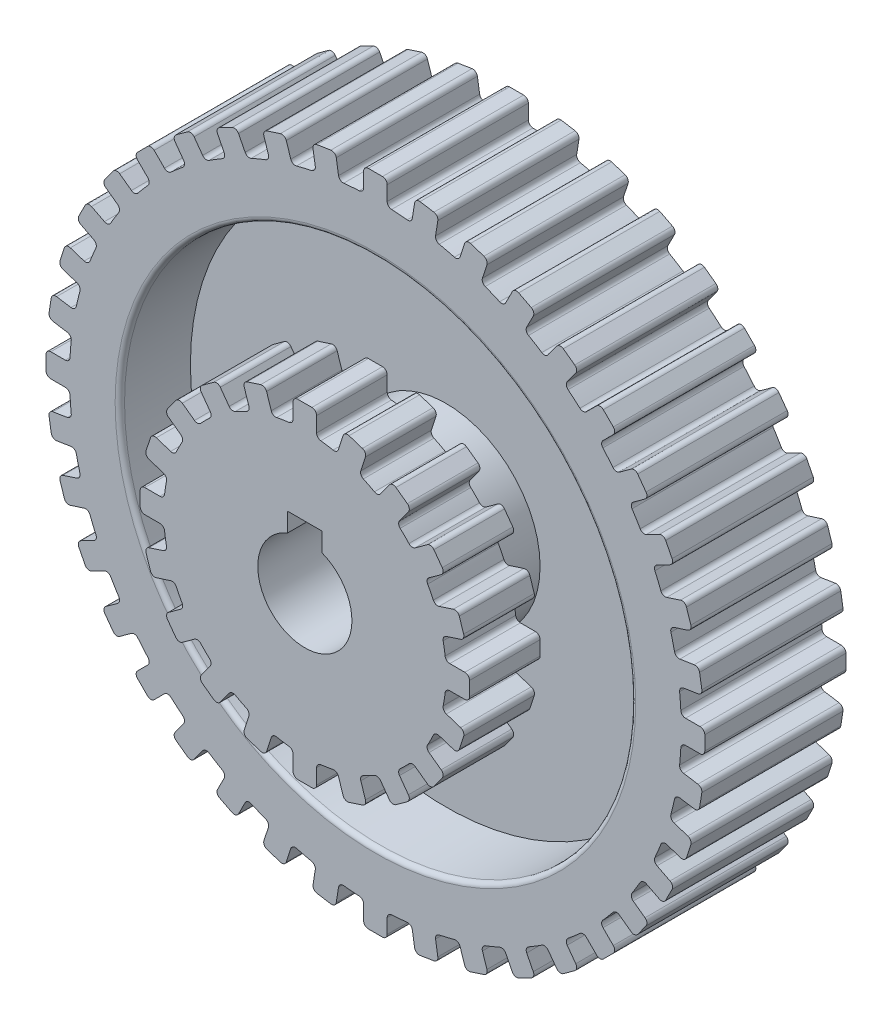
from build123d import *

# Parameters (mm, degrees)
BOSS_EXTRUDE1_DEPTH = 30
CUT_EXTRUDE1_DEPTH  = 30
SKETCH3_R           = 54.321512685
SKETCH3_R_2         = 20
CUT_EXTRUDE2_DEPTH  = 15
FILLET2_R           = 1
BOSS_EXTRUDE2_DEPTH = 15
CUT_EXTRUDE3_DEPTH  = 45


with BuildPart() as part:
    # Sketch1 → Boss-Extrude1 (new body)
    with BuildSketch(Plane.XY):
        with BuildLine():
            Line((8.324757236, 68.541581664), (7.840926028, 65.486791638))
            ThreePointArc((7.840926028, 65.486791638), (7.462274894, 64.85008445), (6.749400752, 64.648631768))
            ThreePointArc((6.749400752, 64.648631768), (5.099841222, 64.799626693), (3.446969697, 64.908538729))
            ThreePointArc((3.446969697, 64.908538729), (2.774386362, 65.219029279), (2.5, 65.907131632))
            Line((2.5, 65.907131632), (2.5, 69))
            ThreePointArc((2.5, 69), (2.207106781, 69.707106781), (1.5, 70))
            Line((1.5, 70), (-1.5, 70))
            ThreePointArc((-1.5, 70), (-2.207106781, 69.707106781), (-2.5, 69))
            Line((-2.5, 69), (-2.5, 65.907131632))
            ThreePointArc((-2.5, 65.907131632), (-2.774386362, 65.219029279), (-3.446969697, 64.908538729))
            ThreePointArc((-3.446969697, 64.908538729), (-5.099841222, 64.799626693), (-6.749400753, 64.648631768))
            ThreePointArc((-6.749400753, 64.648631768), (-7.462274894, 64.85008445), (-7.840926028, 65.486791638))
            Line((-7.840926028, 65.486791638), (-8.324757236, 68.541581664))
            ThreePointArc((-8.324757236, 68.541581664), (-8.724660325, 69.194164193), (-9.468880042, 69.372835539))
            Line((-9.468880042, 69.372835539), (-12.431945064, 68.903532144))
            ThreePointArc((-12.431945064, 68.903532144), (-13.084527593, 68.503629056), (-13.263198939, 67.759409339))
            Line((-13.263198939, 67.759409339), (-12.779367731, 64.704619313))
            ThreePointArc((-12.779367731, 64.704619313), (-12.942733018, 63.982065158), (-13.558464313, 63.570182047))
            ThreePointArc((-13.558464313, 63.570182047), (-15.173948651, 63.204044826), (-16.779578555, 62.796860937))
            ThreePointArc((-16.779578555, 62.796860937), (-17.515190176, 62.884315317), (-17.988782434, 63.453949495))
            Line((-17.988782434, 63.453949495), (-18.944531321, 66.39544211))
            ThreePointArc((-18.944531321, 66.39544211), (-19.441597338, 66.97743164), (-20.204604832, 67.037481632))
            Line((-20.204604832, 67.037481632), (-23.057774381, 66.110430649))
            ThreePointArc((-23.057774381, 66.110430649), (-23.639763911, 65.613364633), (-23.699813903, 64.850357138))
            Line((-23.699813903, 64.850357138), (-22.744065016, 61.908864523))
            ThreePointArc((-22.744065016, 61.908864523), (-22.792386632, 61.169650248), (-23.336104539, 60.666516506))
            ThreePointArc((-23.336104539, 60.666516506), (-24.874423104, 60.052169613), (-26.396587446, 59.398822978))
            ThreePointArc((-26.396587446, 59.398822978), (-27.136823346, 59.37012564), (-27.693695316, 59.858660524))
            Line((-27.693695316, 59.858660524), (-29.097828172, 62.614426418))
            ThreePointArc((-29.097828172, 62.614426418), (-29.679817701, 63.111492435), (-30.442825196, 63.051442443))
            Line((-30.442825196, 63.051442443), (-33.115844768, 61.689470944))
            ThreePointArc((-33.115844768, 61.689470944), (-33.612910785, 61.107481414), (-33.552860793, 60.34447392))
            Line((-33.552860793, 60.34447392), (-32.148727937, 57.588708026))
            ThreePointArc((-32.148727937, 57.588708026), (-32.080816044, 56.851035538), (-32.539132424, 56.269039988))
            ThreePointArc((-32.539132424, 56.269039988), (-33.962406707, 55.421610683), (-35.363624749, 54.538188865))
            ThreePointArc((-35.363624749, 54.538188865), (-36.090257863, 54.394046431), (-36.716697508, 54.789452672))
            Line((-36.716697508, 54.789452672), (-38.534639922, 57.291635743))
            ThreePointArc((-38.534639922, 57.291635743), (-39.187222452, 57.691538831), (-39.931442169, 57.512867485))
            Line((-39.931442169, 57.512867485), (-42.358493152, 55.749511728))
            ThreePointArc((-42.358493152, 55.749511728), (-42.75839624, 55.096929199), (-42.579724894, 54.352709481))
            Line((-42.579724894, 54.352709481), (-40.76178248, 51.85052641))
            ThreePointArc((-40.76178248, 51.85052641), (-40.579309295, 51.132559656), (-40.940938877, 50.486032959))
            ThreePointArc((-40.940938877, 50.486032959), (-42.214123142, 49.426387764), (-43.459892245, 48.334643539))
            ThreePointArc((-43.459892245, 48.334643539), (-44.155030455, 48.078605276), (-44.835612753, 48.371146659))
            Line((-44.835612753, 48.371146659), (-47.022600949, 50.558134855))
            ThreePointArc((-47.022600949, 50.558134855), (-47.72970773, 50.851028074), (-48.436814511, 50.558134855))
            Line((-48.436814511, 50.558134855), (-50.558134855, 48.436814511))
            ThreePointArc((-50.558134855, 48.436814511), (-50.851028074, 47.72970773), (-50.558134855, 47.022600949))
            Line((-50.558134855, 47.022600949), (-48.371146659, 44.835612753))
            ThreePointArc((-48.371146659, 44.835612753), (-48.078605276, 44.155030455), (-48.334643539, 43.459892245))
            ThreePointArc((-48.334643539, 43.459892245), (-49.426387764, 42.214123141), (-50.486032959, 40.940938877))
            ThreePointArc((-50.486032959, 40.940938877), (-51.132559656, 40.579309295), (-51.85052641, 40.76178248))
            Line((-51.85052641, 40.76178248), (-54.352709481, 42.579724894))
            ThreePointArc((-54.352709481, 42.579724894), (-55.096929199, 42.75839624), (-55.749511728, 42.358493152))
            Line((-55.749511728, 42.358493152), (-57.512867485, 39.931442169))
            ThreePointArc((-57.512867485, 39.931442169), (-57.691538831, 39.187222452), (-57.291635743, 38.534639922))
            Line((-57.291635743, 38.534639922), (-54.789452672, 36.716697508))
            ThreePointArc((-54.789452672, 36.716697508), (-54.394046431, 36.090257863), (-54.538188865, 35.363624749))
            ThreePointArc((-54.538188865, 35.363624749), (-55.421610683, 33.962406707), (-56.269039988, 32.539132424))
            ThreePointArc((-56.269039988, 32.539132424), (-56.851035538, 32.080816044), (-57.588708026, 32.148727937))
            Line((-57.588708026, 32.148727937), (-60.34447392, 33.552860793))
            ThreePointArc((-60.34447392, 33.552860793), (-61.107481414, 33.612910785), (-61.689470944, 33.115844768))
            Line((-61.689470944, 33.115844768), (-63.051442443, 30.442825196))
            ThreePointArc((-63.051442443, 30.442825196), (-63.111492435, 29.679817701), (-62.614426418, 29.097828172))
            Line((-62.614426418, 29.097828172), (-59.858660524, 27.693695316))
            ThreePointArc((-59.858660524, 27.693695316), (-59.37012564, 27.136823346), (-59.398822978, 26.396587446))
            ThreePointArc((-59.398822978, 26.396587446), (-60.052169613, 24.874423104), (-60.666516506, 23.336104539))
            ThreePointArc((-60.666516506, 23.336104539), (-61.169650248, 22.792386632), (-61.908864523, 22.744065016))
            Line((-61.908864523, 22.744065016), (-64.850357138, 23.699813903))
            ThreePointArc((-64.850357138, 23.699813903), (-65.613364633, 23.639763911), (-66.110430649, 23.057774381))
            Line((-66.110430649, 23.057774381), (-67.037481632, 20.204604832))
            ThreePointArc((-67.037481632, 20.204604832), (-66.97743164, 19.441597338), (-66.39544211, 18.944531321))
            Line((-66.39544211, 18.944531321), (-63.453949495, 17.988782434))
            ThreePointArc((-63.453949495, 17.988782434), (-62.884315317, 17.515190176), (-62.796860937, 16.779578555))
            ThreePointArc((-62.796860937, 16.779578555), (-63.204044826, 15.173948651), (-63.570182047, 13.558464313))
            ThreePointArc((-63.570182047, 13.558464313), (-63.982065158, 12.942733018), (-64.704619313, 12.779367731))
            Line((-64.704619313, 12.779367731), (-67.759409339, 13.263198939))
            ThreePointArc((-67.759409339, 13.263198939), (-68.503629056, 13.084527593), (-68.903532144, 12.431945064))
            Line((-68.903532144, 12.431945064), (-69.372835539, 9.468880042))
            ThreePointArc((-69.372835539, 9.468880042), (-69.194164193, 8.724660325), (-68.541581664, 8.324757236))
            Line((-68.541581664, 8.324757236), (-65.486791638, 7.840926028))
            ThreePointArc((-65.486791638, 7.840926028), (-64.85008445, 7.462274894), (-64.648631768, 6.749400752))
            ThreePointArc((-64.648631768, 6.749400752), (-64.799626693, 5.099841222), (-64.908538729, 3.446969697))
            ThreePointArc((-64.908538729, 3.446969697), (-65.219029279, 2.774386362), (-65.907131632, 2.5))
            Line((-65.907131632, 2.5), (-69, 2.5))
            ThreePointArc((-69, 2.5), (-69.707106781, 2.207106781), (-70, 1.5))
            Line((-70, 1.5), (-70, -1.5))
            ThreePointArc((-70, -1.5), (-69.707106781, -2.207106781), (-69, -2.5))
            Line((-69, -2.5), (-65.907131632, -2.5))
            ThreePointArc((-65.907131632, -2.5), (-65.219029279, -2.774386362), (-64.908538729, -3.446969697))
            ThreePointArc((-64.908538729, -3.446969697), (-64.799626693, -5.099841222), (-64.648631768, -6.749400753))
            ThreePointArc((-64.648631768, -6.749400753), (-64.85008445, -7.462274894), (-65.486791638, -7.840926028))
            Line((-65.486791638, -7.840926028), (-68.541581664, -8.324757236))
            ThreePointArc((-68.541581664, -8.324757236), (-69.194164193, -8.724660325), (-69.372835539, -9.468880042))
            Line((-69.372835539, -9.468880042), (-68.903532144, -12.431945064))
            ThreePointArc((-68.903532144, -12.431945064), (-68.503629056, -13.084527593), (-67.759409339, -13.263198939))
            Line((-67.759409339, -13.263198939), (-64.704619313, -12.779367731))
            ThreePointArc((-64.704619313, -12.779367731), (-63.982065158, -12.942733018), (-63.570182047, -13.558464313))
            ThreePointArc((-63.570182047, -13.558464313), (-63.204044826, -15.173948651), (-62.796860937, -16.779578555))
            ThreePointArc((-62.796860937, -16.779578555), (-62.884315317, -17.515190176), (-63.453949495, -17.988782434))
            Line((-63.453949495, -17.988782434), (-66.39544211, -18.944531321))
            ThreePointArc((-66.39544211, -18.944531321), (-66.97743164, -19.441597338), (-67.037481632, -20.204604832))
            Line((-67.037481632, -20.204604832), (-66.110430649, -23.057774381))
            ThreePointArc((-66.110430649, -23.057774381), (-65.613364633, -23.639763911), (-64.850357138, -23.699813903))
            Line((-64.850357138, -23.699813903), (-61.908864523, -22.744065016))
            ThreePointArc((-61.908864523, -22.744065016), (-61.169650248, -22.792386632), (-60.666516506, -23.336104539))
            ThreePointArc((-60.666516506, -23.336104539), (-60.052169613, -24.874423104), (-59.398822978, -26.396587446))
            ThreePointArc((-59.398822978, -26.396587446), (-59.37012564, -27.136823346), (-59.858660524, -27.693695316))
            Line((-59.858660524, -27.693695316), (-62.614426418, -29.097828172))
            ThreePointArc((-62.614426418, -29.097828172), (-63.111492435, -29.679817701), (-63.051442443, -30.442825196))
            Line((-63.051442443, -30.442825196), (-61.689470944, -33.115844768))
            ThreePointArc((-61.689470944, -33.115844768), (-61.107481414, -33.612910785), (-60.34447392, -33.552860793))
            Line((-60.34447392, -33.552860793), (-57.588708026, -32.148727937))
            ThreePointArc((-57.588708026, -32.148727937), (-56.851035538, -32.080816044), (-56.269039988, -32.539132424))
            ThreePointArc((-56.269039988, -32.539132424), (-55.421610683, -33.962406707), (-54.538188865, -35.363624749))
            ThreePointArc((-54.538188865, -35.363624749), (-54.394046431, -36.090257863), (-54.789452672, -36.716697508))
            Line((-54.789452672, -36.716697508), (-57.291635743, -38.534639922))
            ThreePointArc((-57.291635743, -38.534639922), (-57.691538831, -39.187222452), (-57.512867485, -39.931442169))
            Line((-57.512867485, -39.931442169), (-55.749511728, -42.358493152))
            ThreePointArc((-55.749511728, -42.358493152), (-55.096929199, -42.75839624), (-54.352709481, -42.579724894))
            Line((-54.352709481, -42.579724894), (-51.85052641, -40.76178248))
            ThreePointArc((-51.85052641, -40.76178248), (-51.132559656, -40.579309295), (-50.486032959, -40.940938877))
            ThreePointArc((-50.486032959, -40.940938877), (-49.426387764, -42.214123142), (-48.334643539, -43.459892245))
            ThreePointArc((-48.334643539, -43.459892245), (-48.078605276, -44.155030455), (-48.371146659, -44.835612753))
            Line((-48.371146659, -44.835612753), (-50.558134855, -47.022600949))
            ThreePointArc((-50.558134855, -47.022600949), (-50.851028074, -47.72970773), (-50.558134855, -48.436814511))
            Line((-50.558134855, -48.436814511), (-48.436814511, -50.558134855))
            ThreePointArc((-48.436814511, -50.558134855), (-47.72970773, -50.851028074), (-47.022600949, -50.558134855))
            Line((-47.022600949, -50.558134855), (-44.835612753, -48.371146659))
            ThreePointArc((-44.835612753, -48.371146659), (-44.155030455, -48.078605276), (-43.459892245, -48.334643539))
            ThreePointArc((-43.459892245, -48.334643539), (-42.214123141, -49.426387764), (-40.940938877, -50.486032959))
            ThreePointArc((-40.940938877, -50.486032959), (-40.579309295, -51.132559656), (-40.76178248, -51.85052641))
            Line((-40.76178248, -51.85052641), (-42.579724894, -54.352709481))
            ThreePointArc((-42.579724894, -54.352709481), (-42.75839624, -55.096929199), (-42.358493152, -55.749511728))
            Line((-42.358493152, -55.749511728), (-39.931442169, -57.512867485))
            ThreePointArc((-39.931442169, -57.512867485), (-39.187222452, -57.691538831), (-38.534639922, -57.291635743))
            Line((-38.534639922, -57.291635743), (-36.716697508, -54.789452672))
            ThreePointArc((-36.716697508, -54.789452672), (-36.090257863, -54.394046431), (-35.363624749, -54.538188865))
            ThreePointArc((-35.363624749, -54.538188865), (-33.962406707, -55.421610683), (-32.539132424, -56.269039988))
            ThreePointArc((-32.539132424, -56.269039988), (-32.080816044, -56.851035538), (-32.148727937, -57.588708026))
            Line((-32.148727937, -57.588708026), (-33.552860793, -60.34447392))
            ThreePointArc((-33.552860793, -60.34447392), (-33.612910785, -61.107481414), (-33.115844768, -61.689470944))
            Line((-33.115844768, -61.689470944), (-30.442825196, -63.051442443))
            ThreePointArc((-30.442825196, -63.051442443), (-29.679817701, -63.111492435), (-29.097828172, -62.614426418))
            Line((-29.097828172, -62.614426418), (-27.693695316, -59.858660524))
            ThreePointArc((-27.693695316, -59.858660524), (-27.136823346, -59.37012564), (-26.396587446, -59.398822978))
            ThreePointArc((-26.396587446, -59.398822978), (-24.874423104, -60.052169613), (-23.336104539, -60.666516506))
            ThreePointArc((-23.336104539, -60.666516506), (-22.792386632, -61.169650248), (-22.744065016, -61.908864523))
            Line((-22.744065016, -61.908864523), (-23.699813903, -64.850357138))
            ThreePointArc((-23.699813903, -64.850357138), (-23.639763911, -65.613364633), (-23.057774381, -66.110430649))
            Line((-23.057774381, -66.110430649), (-20.204604832, -67.037481632))
            ThreePointArc((-20.204604832, -67.037481632), (-19.441597338, -66.97743164), (-18.944531321, -66.39544211))
            Line((-18.944531321, -66.39544211), (-17.988782434, -63.453949495))
            ThreePointArc((-17.988782434, -63.453949495), (-17.515190176, -62.884315317), (-16.779578555, -62.796860937))
            ThreePointArc((-16.779578555, -62.796860937), (-15.173948651, -63.204044826), (-13.558464313, -63.570182047))
            ThreePointArc((-13.558464313, -63.570182047), (-12.942733018, -63.982065158), (-12.779367731, -64.704619313))
            Line((-12.779367731, -64.704619313), (-13.263198939, -67.759409339))
            ThreePointArc((-13.263198939, -67.759409339), (-13.084527593, -68.503629056), (-12.431945064, -68.903532144))
            Line((-12.431945064, -68.903532144), (-9.468880042, -69.372835539))
            ThreePointArc((-9.468880042, -69.372835539), (-8.724660325, -69.194164193), (-8.324757236, -68.541581664))
            Line((-8.324757236, -68.541581664), (-7.840926028, -65.486791638))
            ThreePointArc((-7.840926028, -65.486791638), (-7.462274894, -64.85008445), (-6.749400752, -64.648631768))
            ThreePointArc((-6.749400752, -64.648631768), (-5.099841222, -64.799626693), (-3.446969697, -64.908538729))
            ThreePointArc((-3.446969697, -64.908538729), (-2.774386362, -65.219029279), (-2.5, -65.907131632))
            Line((-2.5, -65.907131632), (-2.5, -69))
            ThreePointArc((-2.5, -69), (-2.207106781, -69.707106781), (-1.5, -70))
            Line((-1.5, -70), (1.5, -70))
            ThreePointArc((1.5, -70), (2.207106781, -69.707106781), (2.5, -69))
            Line((2.5, -69), (2.5, -65.907131632))
            ThreePointArc((2.5, -65.907131632), (2.774386362, -65.219029279), (3.446969697, -64.908538729))
            ThreePointArc((3.446969697, -64.908538729), (5.099841222, -64.799626693), (6.749400753, -64.648631768))
            ThreePointArc((6.749400753, -64.648631768), (7.462274894, -64.85008445), (7.840926028, -65.486791638))
            Line((7.840926028, -65.486791638), (8.324757236, -68.541581664))
            ThreePointArc((8.324757236, -68.541581664), (8.724660325, -69.194164193), (9.468880042, -69.372835539))
            Line((9.468880042, -69.372835539), (12.431945064, -68.903532144))
            ThreePointArc((12.431945064, -68.903532144), (13.084527593, -68.503629056), (13.263198939, -67.759409339))
            Line((13.263198939, -67.759409339), (12.779367731, -64.704619313))
            ThreePointArc((12.779367731, -64.704619313), (12.942733018, -63.982065158), (13.558464313, -63.570182047))
            ThreePointArc((13.558464313, -63.570182047), (15.173948651, -63.204044826), (16.779578555, -62.796860937))
            ThreePointArc((16.779578555, -62.796860937), (17.515190176, -62.884315317), (17.988782434, -63.453949495))
            Line((17.988782434, -63.453949495), (18.944531321, -66.39544211))
            ThreePointArc((18.944531321, -66.39544211), (19.441597338, -66.97743164), (20.204604832, -67.037481632))
            Line((20.204604832, -67.037481632), (23.057774381, -66.110430649))
            ThreePointArc((23.057774381, -66.110430649), (23.639763911, -65.613364633), (23.699813903, -64.850357138))
            Line((23.699813903, -64.850357138), (22.744065016, -61.908864523))
            ThreePointArc((22.744065016, -61.908864523), (22.792386632, -61.169650248), (23.336104539, -60.666516506))
            ThreePointArc((23.336104539, -60.666516506), (24.874423104, -60.052169613), (26.396587446, -59.398822978))
            ThreePointArc((26.396587446, -59.398822978), (27.136823346, -59.37012564), (27.693695316, -59.858660524))
            Line((27.693695316, -59.858660524), (29.097828172, -62.614426418))
            ThreePointArc((29.097828172, -62.614426418), (29.679817701, -63.111492435), (30.442825196, -63.051442443))
            Line((30.442825196, -63.051442443), (33.115844768, -61.689470944))
            ThreePointArc((33.115844768, -61.689470944), (33.612910785, -61.107481414), (33.552860793, -60.34447392))
            Line((33.552860793, -60.34447392), (32.148727937, -57.588708026))
            ThreePointArc((32.148727937, -57.588708026), (32.080816044, -56.851035538), (32.539132424, -56.269039988))
            ThreePointArc((32.539132424, -56.269039988), (33.962406707, -55.421610683), (35.363624749, -54.538188865))
            ThreePointArc((35.363624749, -54.538188865), (36.090257863, -54.394046431), (36.716697508, -54.789452672))
            Line((36.716697508, -54.789452672), (38.534639922, -57.291635743))
            ThreePointArc((38.534639922, -57.291635743), (39.187222452, -57.691538831), (39.931442169, -57.512867485))
            Line((39.931442169, -57.512867485), (42.358493152, -55.749511728))
            ThreePointArc((42.358493152, -55.749511728), (42.75839624, -55.096929199), (42.579724894, -54.352709481))
            Line((42.579724894, -54.352709481), (40.76178248, -51.85052641))
            ThreePointArc((40.76178248, -51.85052641), (40.579309295, -51.132559656), (40.940938877, -50.486032959))
            ThreePointArc((40.940938877, -50.486032959), (42.214123142, -49.426387764), (43.459892245, -48.334643539))
            ThreePointArc((43.459892245, -48.334643539), (44.155030455, -48.078605276), (44.835612753, -48.371146659))
            Line((44.835612753, -48.371146659), (47.022600949, -50.558134855))
            ThreePointArc((47.022600949, -50.558134855), (47.72970773, -50.851028074), (48.436814511, -50.558134855))
            Line((48.436814511, -50.558134855), (50.558134855, -48.436814511))
            ThreePointArc((50.558134855, -48.436814511), (50.851028074, -47.72970773), (50.558134855, -47.022600949))
            Line((50.558134855, -47.022600949), (48.371146659, -44.835612753))
            ThreePointArc((48.371146659, -44.835612753), (48.078605276, -44.155030455), (48.334643539, -43.459892245))
            ThreePointArc((48.334643539, -43.459892245), (49.426387764, -42.214123141), (50.486032959, -40.940938877))
            ThreePointArc((50.486032959, -40.940938877), (51.132559656, -40.579309295), (51.85052641, -40.76178248))
            Line((51.85052641, -40.76178248), (54.352709481, -42.579724894))
            ThreePointArc((54.352709481, -42.579724894), (55.096929199, -42.75839624), (55.749511728, -42.358493152))
            Line((55.749511728, -42.358493152), (57.512867485, -39.931442169))
            ThreePointArc((57.512867485, -39.931442169), (57.691538831, -39.187222452), (57.291635743, -38.534639922))
            Line((57.291635743, -38.534639922), (54.789452672, -36.716697508))
            ThreePointArc((54.789452672, -36.716697508), (54.394046431, -36.090257863), (54.538188865, -35.363624749))
            ThreePointArc((54.538188865, -35.363624749), (55.421610683, -33.962406707), (56.269039988, -32.539132424))
            ThreePointArc((56.269039988, -32.539132424), (56.851035538, -32.080816044), (57.588708026, -32.148727937))
            Line((57.588708026, -32.148727937), (60.34447392, -33.552860793))
            ThreePointArc((60.34447392, -33.552860793), (61.107481414, -33.612910785), (61.689470944, -33.115844768))
            Line((61.689470944, -33.115844768), (63.051442443, -30.442825196))
            ThreePointArc((63.051442443, -30.442825196), (63.111492435, -29.679817701), (62.614426418, -29.097828172))
            Line((62.614426418, -29.097828172), (59.858660524, -27.693695316))
            ThreePointArc((59.858660524, -27.693695316), (59.37012564, -27.136823346), (59.398822978, -26.396587446))
            ThreePointArc((59.398822978, -26.396587446), (60.052169613, -24.874423104), (60.666516506, -23.336104539))
            ThreePointArc((60.666516506, -23.336104539), (61.169650248, -22.792386632), (61.908864523, -22.744065016))
            Line((61.908864523, -22.744065016), (64.850357138, -23.699813903))
            ThreePointArc((64.850357138, -23.699813903), (65.613364633, -23.639763911), (66.110430649, -23.057774381))
            Line((66.110430649, -23.057774381), (67.037481632, -20.204604832))
            ThreePointArc((67.037481632, -20.204604832), (66.97743164, -19.441597338), (66.39544211, -18.944531321))
            Line((66.39544211, -18.944531321), (63.453949495, -17.988782434))
            ThreePointArc((63.453949495, -17.988782434), (62.884315317, -17.515190176), (62.796860937, -16.779578555))
            ThreePointArc((62.796860937, -16.779578555), (63.204044826, -15.173948651), (63.570182047, -13.558464313))
            ThreePointArc((63.570182047, -13.558464313), (63.982065158, -12.942733018), (64.704619313, -12.779367731))
            Line((64.704619313, -12.779367731), (67.759409339, -13.263198939))
            ThreePointArc((67.759409339, -13.263198939), (68.503629056, -13.084527593), (68.903532144, -12.431945064))
            Line((68.903532144, -12.431945064), (69.372835539, -9.468880042))
            ThreePointArc((69.372835539, -9.468880042), (69.194164193, -8.724660325), (68.541581664, -8.324757236))
            Line((68.541581664, -8.324757236), (65.486791638, -7.840926028))
            ThreePointArc((65.486791638, -7.840926028), (64.85008445, -7.462274894), (64.648631768, -6.749400752))
            ThreePointArc((64.648631768, -6.749400752), (64.799626693, -5.099841222), (64.908538729, -3.446969697))
            ThreePointArc((64.908538729, -3.446969697), (65.219029279, -2.774386362), (65.907131632, -2.5))
            Line((65.907131632, -2.5), (69, -2.5))
            ThreePointArc((69, -2.5), (69.707106781, -2.207106781), (70, -1.5))
            Line((70, -1.5), (70, 1.5))
            ThreePointArc((70, 1.5), (69.707106781, 2.207106781), (69, 2.5))
            Line((69, 2.5), (65.907131632, 2.5))
            ThreePointArc((65.907131632, 2.5), (65.219029279, 2.774386362), (64.908538729, 3.446969697))
            ThreePointArc((64.908538729, 3.446969697), (64.799626693, 5.099841222), (64.648631768, 6.749400753))
            ThreePointArc((64.648631768, 6.749400753), (64.85008445, 7.462274894), (65.486791638, 7.840926028))
            Line((65.486791638, 7.840926028), (68.541581664, 8.324757236))
            ThreePointArc((68.541581664, 8.324757236), (69.194164193, 8.724660325), (69.372835539, 9.468880042))
            Line((69.372835539, 9.468880042), (68.903532144, 12.431945064))
            ThreePointArc((68.903532144, 12.431945064), (68.503629056, 13.084527593), (67.759409339, 13.263198939))
            Line((67.759409339, 13.263198939), (64.704619313, 12.779367731))
            ThreePointArc((64.704619313, 12.779367731), (63.982065158, 12.942733018), (63.570182047, 13.558464313))
            ThreePointArc((63.570182047, 13.558464313), (63.204044826, 15.173948651), (62.796860937, 16.779578555))
            ThreePointArc((62.796860937, 16.779578555), (62.884315317, 17.515190176), (63.453949495, 17.988782434))
            Line((63.453949495, 17.988782434), (66.39544211, 18.944531321))
            ThreePointArc((66.39544211, 18.944531321), (66.97743164, 19.441597338), (67.037481632, 20.204604832))
            Line((67.037481632, 20.204604832), (66.110430649, 23.057774381))
            ThreePointArc((66.110430649, 23.057774381), (65.613364633, 23.639763911), (64.850357138, 23.699813903))
            Line((64.850357138, 23.699813903), (61.908864523, 22.744065016))
            ThreePointArc((61.908864523, 22.744065016), (61.169650248, 22.792386632), (60.666516506, 23.336104539))
            ThreePointArc((60.666516506, 23.336104539), (60.052169613, 24.874423104), (59.398822978, 26.396587446))
            ThreePointArc((59.398822978, 26.396587446), (59.37012564, 27.136823346), (59.858660524, 27.693695316))
            Line((59.858660524, 27.693695316), (62.614426418, 29.097828172))
            ThreePointArc((62.614426418, 29.097828172), (63.111492435, 29.679817701), (63.051442443, 30.442825196))
            Line((63.051442443, 30.442825196), (61.689470944, 33.115844768))
            ThreePointArc((61.689470944, 33.115844768), (61.107481414, 33.612910785), (60.34447392, 33.552860793))
            Line((60.34447392, 33.552860793), (57.588708026, 32.148727937))
            ThreePointArc((57.588708026, 32.148727937), (56.851035538, 32.080816044), (56.269039988, 32.539132424))
            ThreePointArc((56.269039988, 32.539132424), (55.421610683, 33.962406707), (54.538188865, 35.363624749))
            ThreePointArc((54.538188865, 35.363624749), (54.394046431, 36.090257863), (54.789452672, 36.716697508))
            Line((54.789452672, 36.716697508), (57.291635743, 38.534639922))
            ThreePointArc((57.291635743, 38.534639922), (57.691538831, 39.187222452), (57.512867485, 39.931442169))
            Line((57.512867485, 39.931442169), (55.749511728, 42.358493152))
            ThreePointArc((55.749511728, 42.358493152), (55.096929199, 42.75839624), (54.352709481, 42.579724894))
            Line((54.352709481, 42.579724894), (51.85052641, 40.76178248))
            ThreePointArc((51.85052641, 40.76178248), (51.132559656, 40.579309295), (50.486032959, 40.940938877))
            ThreePointArc((50.486032959, 40.940938877), (49.426387764, 42.214123142), (48.334643539, 43.459892245))
            ThreePointArc((48.334643539, 43.459892245), (48.078605276, 44.155030455), (48.371146659, 44.835612753))
            Line((48.371146659, 44.835612753), (50.558134855, 47.022600949))
            ThreePointArc((50.558134855, 47.022600949), (50.851028074, 47.72970773), (50.558134855, 48.436814511))
            Line((50.558134855, 48.436814511), (48.436814511, 50.558134855))
            ThreePointArc((48.436814511, 50.558134855), (47.72970773, 50.851028074), (47.022600949, 50.558134855))
            Line((47.022600949, 50.558134855), (44.835612753, 48.371146659))
            ThreePointArc((44.835612753, 48.371146659), (44.155030455, 48.078605276), (43.459892245, 48.334643539))
            ThreePointArc((43.459892245, 48.334643539), (42.214123141, 49.426387764), (40.940938877, 50.486032959))
            ThreePointArc((40.940938877, 50.486032959), (40.579309295, 51.132559656), (40.76178248, 51.85052641))
            Line((40.76178248, 51.85052641), (42.579724894, 54.352709481))
            ThreePointArc((42.579724894, 54.352709481), (42.75839624, 55.096929199), (42.358493152, 55.749511728))
            Line((42.358493152, 55.749511728), (39.931442169, 57.512867485))
            ThreePointArc((39.931442169, 57.512867485), (39.187222452, 57.691538831), (38.534639922, 57.291635743))
            Line((38.534639922, 57.291635743), (36.716697508, 54.789452672))
            ThreePointArc((36.716697508, 54.789452672), (36.090257863, 54.394046431), (35.363624749, 54.538188865))
            ThreePointArc((35.363624749, 54.538188865), (33.962406707, 55.421610683), (32.539132424, 56.269039988))
            ThreePointArc((32.539132424, 56.269039988), (32.080816044, 56.851035538), (32.148727937, 57.588708026))
            Line((32.148727937, 57.588708026), (33.552860793, 60.34447392))
            ThreePointArc((33.552860793, 60.34447392), (33.612910785, 61.107481414), (33.115844768, 61.689470944))
            Line((33.115844768, 61.689470944), (30.442825196, 63.051442443))
            ThreePointArc((30.442825196, 63.051442443), (29.679817701, 63.111492435), (29.097828172, 62.614426418))
            Line((29.097828172, 62.614426418), (27.693695316, 59.858660524))
            ThreePointArc((27.693695316, 59.858660524), (27.136823346, 59.37012564), (26.396587446, 59.398822978))
            ThreePointArc((26.396587446, 59.398822978), (24.874423104, 60.052169613), (23.336104539, 60.666516506))
            ThreePointArc((23.336104539, 60.666516506), (22.792386632, 61.169650248), (22.744065016, 61.908864523))
            Line((22.744065016, 61.908864523), (23.699813903, 64.850357138))
            ThreePointArc((23.699813903, 64.850357138), (23.639763911, 65.613364633), (23.057774381, 66.110430649))
            Line((23.057774381, 66.110430649), (20.204604832, 67.037481632))
            ThreePointArc((20.204604832, 67.037481632), (19.441597338, 66.97743164), (18.944531321, 66.39544211))
            Line((18.944531321, 66.39544211), (17.988782434, 63.453949495))
            ThreePointArc((17.988782434, 63.453949495), (17.515190176, 62.884315317), (16.779578555, 62.796860937))
            ThreePointArc((16.779578555, 62.796860937), (15.173948651, 63.204044826), (13.558464313, 63.570182047))
            ThreePointArc((13.558464313, 63.570182047), (12.942733018, 63.982065158), (12.779367731, 64.704619313))
            Line((12.779367731, 64.704619313), (13.263198939, 67.759409339))
            ThreePointArc((13.263198939, 67.759409339), (13.084527593, 68.503629056), (12.431945064, 68.903532144))
            Line((12.431945064, 68.903532144), (9.468880042, 69.372835539))
            ThreePointArc((9.468880042, 69.372835539), (8.724660325, 69.194164193), (8.324757236, 68.541581664))
        make_face()
    extrude(amount=BOSS_EXTRUDE1_DEPTH)

    # Sketch2 → Cut-Extrude1 (cut)
    with BuildSketch(Plane.XY.offset(30)):
        with BuildLine():
            Line((-3.538659763, 13.11467819), (3.538659763, 13.11467819))
            Line((3.538659763, 13.11467819), (3.538659763, 9.352961407))
            ThreePointArc((3.538659763, 9.352961407), (0, -10), (-3.538659763, 9.352961407))
            Line((-3.538659763, 9.352961407), (-3.538659763, 13.11467819))
        make_face()
    extrude(amount=-CUT_EXTRUDE1_DEPTH, mode=Mode.SUBTRACT)

    # Sketch3 → Cut-Extrude2 (cut)
    with BuildSketch(Plane.XY.offset(30)):
        Circle(SKETCH3_R)
        Circle(SKETCH3_R_2, mode=Mode.SUBTRACT)
    extrude(amount=-CUT_EXTRUDE2_DEPTH, mode=Mode.SUBTRACT)

    # Fillet2
    fillet2_edges = [part.edges().sort_by_distance(p)[0] for p in [
        (-54.321512685, 0, 30),
    ]]
    fillet(fillet2_edges, radius=FILLET2_R)

    # Sketch4 → Boss-Extrude2 (add)
    with BuildSketch(Plane.XY.offset(30)):
        with BuildLine():
            Line((8.128936518, 33.10846404), (7.140633936, 30.066781454))
            ThreePointArc((7.140633936, 30.066781454), (6.693220985, 29.511886902), (5.989913632, 29.395933982))
            ThreePointArc((5.989913632, 29.395933982), (4.693033951, 29.630650218), (3.387096774, 29.808179673))
            ThreePointArc((3.387096774, 29.808179673), (2.754043156, 30.135791378), (2.5, 30.801785663))
            Line((2.5, 30.801785663), (2.5, 34))
            ThreePointArc((2.5, 34), (2.207106781, 34.707106781), (1.5, 35))
            Line((1.5, 35), (-1.5, 35))
            ThreePointArc((-1.5, 35), (-2.207106781, 34.707106781), (-2.5, 34))
            Line((-2.5, 34), (-2.5, 30.801785663))
            ThreePointArc((-2.5, 30.801785663), (-2.754043156, 30.135791378), (-3.387096774, 29.808179673))
            ThreePointArc((-3.387096774, 29.808179673), (-4.693033951, 29.630650218), (-5.989913632, 29.395933982))
            ThreePointArc((-5.989913632, 29.395933982), (-6.693220985, 29.511886902), (-7.140633936, 30.066781454))
            Line((-7.140633936, 30.066781454), (-8.128936518, 33.10846404))
            ThreePointArc((-8.128936518, 33.10846404), (-8.626002535, 33.69045357), (-9.389010029, 33.750503562))
            Line((-9.389010029, 33.750503562), (-12.242179578, 32.823452579))
            ThreePointArc((-12.242179578, 32.823452579), (-12.824169107, 32.326386562), (-12.884219099, 31.563379068))
            Line((-12.884219099, 31.563379068), (-11.895916518, 28.521696482))
            ThreePointArc((-11.895916518, 28.521696482), (-11.931722365, 27.809794625), (-12.432554549, 27.302593052))
            ThreePointArc((-12.432554549, 27.302593052), (-13.619714992, 26.730195726), (-14.780589558, 26.106209459))
            ThreePointArc((-14.780589558, 26.106209459), (-15.485306022, 25.999153315), (-16.082292871, 26.388631189))
            Line((-16.082292871, 26.388631189), (-17.962156092, 28.976040939))
            ThreePointArc((-17.962156092, 28.976040939), (-18.614738621, 29.375944028), (-19.358958339, 29.197272682))
            Line((-19.358958339, 29.197272682), (-21.786009322, 27.433916925))
            ThreePointArc((-21.786009322, 27.433916925), (-22.18591241, 26.781334395), (-22.007241064, 26.037114678))
            Line((-22.007241064, 26.037114678), (-20.127377843, 23.449704927))
            ThreePointArc((-20.127377843, 23.449704927), (-19.941441455, 22.761581412), (-20.261027262, 22.124438395))
            ThreePointArc((-20.261027262, 22.124438395), (-21.213203436, 21.213203436), (-22.124438395, 20.261027262))
            ThreePointArc((-22.124438395, 20.261027262), (-22.761581412, 19.941441455), (-23.449704927, 20.127377843))
            Line((-23.449704927, 20.127377843), (-26.037114678, 22.007241064))
            ThreePointArc((-26.037114678, 22.007241064), (-26.781334395, 22.18591241), (-27.433916925, 21.786009322))
            Line((-27.433916925, 21.786009322), (-29.197272682, 19.358958339))
            ThreePointArc((-29.197272682, 19.358958339), (-29.375944028, 18.614738621), (-28.976040939, 17.962156092))
            Line((-28.976040939, 17.962156092), (-26.388631189, 16.082292871))
            ThreePointArc((-26.388631189, 16.082292871), (-25.999153315, 15.485306022), (-26.106209459, 14.780589558))
            ThreePointArc((-26.106209459, 14.780589558), (-26.730195726, 13.619714992), (-27.302593052, 12.432554549))
            ThreePointArc((-27.302593052, 12.432554549), (-27.809794625, 11.931722365), (-28.521696482, 11.895916518))
            Line((-28.521696482, 11.895916518), (-31.563379068, 12.884219099))
            ThreePointArc((-31.563379068, 12.884219099), (-32.326386562, 12.824169107), (-32.823452579, 12.242179578))
            Line((-32.823452579, 12.242179578), (-33.750503562, 9.389010029))
            ThreePointArc((-33.750503562, 9.389010029), (-33.69045357, 8.626002535), (-33.10846404, 8.128936518))
            Line((-33.10846404, 8.128936518), (-30.066781454, 7.140633936))
            ThreePointArc((-30.066781454, 7.140633936), (-29.511886902, 6.693220985), (-29.395933982, 5.989913632))
            ThreePointArc((-29.395933982, 5.989913632), (-29.630650218, 4.693033951), (-29.808179673, 3.387096774))
            ThreePointArc((-29.808179673, 3.387096774), (-30.135791378, 2.754043156), (-30.801785663, 2.5))
            Line((-30.801785663, 2.5), (-34, 2.5))
            ThreePointArc((-34, 2.5), (-34.707106781, 2.207106781), (-35, 1.5))
            Line((-35, 1.5), (-35, -1.5))
            ThreePointArc((-35, -1.5), (-34.707106781, -2.207106781), (-34, -2.5))
            Line((-34, -2.5), (-30.801785663, -2.5))
            ThreePointArc((-30.801785663, -2.5), (-30.135791378, -2.754043156), (-29.808179673, -3.387096774))
            ThreePointArc((-29.808179673, -3.387096774), (-29.630650218, -4.693033951), (-29.395933982, -5.989913632))
            ThreePointArc((-29.395933982, -5.989913632), (-29.511886902, -6.693220985), (-30.066781454, -7.140633936))
            Line((-30.066781454, -7.140633936), (-33.10846404, -8.128936518))
            ThreePointArc((-33.10846404, -8.128936518), (-33.69045357, -8.626002535), (-33.750503562, -9.389010029))
            Line((-33.750503562, -9.389010029), (-32.823452579, -12.242179578))
            ThreePointArc((-32.823452579, -12.242179578), (-32.326386562, -12.824169107), (-31.563379068, -12.884219099))
            Line((-31.563379068, -12.884219099), (-28.521696482, -11.895916518))
            ThreePointArc((-28.521696482, -11.895916518), (-27.809794625, -11.931722365), (-27.302593052, -12.432554549))
            ThreePointArc((-27.302593052, -12.432554549), (-26.730195726, -13.619714992), (-26.106209459, -14.780589558))
            ThreePointArc((-26.106209459, -14.780589558), (-25.999153315, -15.485306022), (-26.388631189, -16.082292871))
            Line((-26.388631189, -16.082292871), (-28.976040939, -17.962156092))
            ThreePointArc((-28.976040939, -17.962156092), (-29.375944028, -18.614738621), (-29.197272682, -19.358958339))
            Line((-29.197272682, -19.358958339), (-27.433916925, -21.786009322))
            ThreePointArc((-27.433916925, -21.786009322), (-26.781334395, -22.18591241), (-26.037114678, -22.007241064))
            Line((-26.037114678, -22.007241064), (-23.449704927, -20.127377843))
            ThreePointArc((-23.449704927, -20.127377843), (-22.761581412, -19.941441455), (-22.124438395, -20.261027262))
            ThreePointArc((-22.124438395, -20.261027262), (-21.213203436, -21.213203436), (-20.261027262, -22.124438395))
            ThreePointArc((-20.261027262, -22.124438395), (-19.941441455, -22.761581412), (-20.127377843, -23.449704927))
            Line((-20.127377843, -23.449704927), (-22.007241064, -26.037114678))
            ThreePointArc((-22.007241064, -26.037114678), (-22.18591241, -26.781334395), (-21.786009322, -27.433916925))
            Line((-21.786009322, -27.433916925), (-19.358958339, -29.197272682))
            ThreePointArc((-19.358958339, -29.197272682), (-18.614738621, -29.375944028), (-17.962156092, -28.976040939))
            Line((-17.962156092, -28.976040939), (-16.082292871, -26.388631189))
            ThreePointArc((-16.082292871, -26.388631189), (-15.485306022, -25.999153315), (-14.780589558, -26.106209459))
            ThreePointArc((-14.780589558, -26.106209459), (-13.619714992, -26.730195726), (-12.432554549, -27.302593052))
            ThreePointArc((-12.432554549, -27.302593052), (-11.931722365, -27.809794625), (-11.895916518, -28.521696482))
            Line((-11.895916518, -28.521696482), (-12.884219099, -31.563379068))
            ThreePointArc((-12.884219099, -31.563379068), (-12.824169107, -32.326386562), (-12.242179578, -32.823452579))
            Line((-12.242179578, -32.823452579), (-9.389010029, -33.750503562))
            ThreePointArc((-9.389010029, -33.750503562), (-8.626002535, -33.69045357), (-8.128936518, -33.10846404))
            Line((-8.128936518, -33.10846404), (-7.140633936, -30.066781454))
            ThreePointArc((-7.140633936, -30.066781454), (-6.693220985, -29.511886902), (-5.989913632, -29.395933982))
            ThreePointArc((-5.989913632, -29.395933982), (-4.693033951, -29.630650218), (-3.387096774, -29.808179673))
            ThreePointArc((-3.387096774, -29.808179673), (-2.754043156, -30.135791378), (-2.5, -30.801785663))
            Line((-2.5, -30.801785663), (-2.5, -34))
            ThreePointArc((-2.5, -34), (-2.207106781, -34.707106781), (-1.5, -35))
            Line((-1.5, -35), (1.5, -35))
            ThreePointArc((1.5, -35), (2.207106781, -34.707106781), (2.5, -34))
            Line((2.5, -34), (2.5, -30.801785663))
            ThreePointArc((2.5, -30.801785663), (2.754043156, -30.135791378), (3.387096774, -29.808179673))
            ThreePointArc((3.387096774, -29.808179673), (4.693033951, -29.630650218), (5.989913632, -29.395933982))
            ThreePointArc((5.989913632, -29.395933982), (6.693220985, -29.511886902), (7.140633936, -30.066781454))
            Line((7.140633936, -30.066781454), (8.128936518, -33.10846404))
            ThreePointArc((8.128936518, -33.10846404), (8.626002535, -33.69045357), (9.389010029, -33.750503562))
            Line((9.389010029, -33.750503562), (12.242179578, -32.823452579))
            ThreePointArc((12.242179578, -32.823452579), (12.824169107, -32.326386562), (12.884219099, -31.563379068))
            Line((12.884219099, -31.563379068), (11.895916518, -28.521696482))
            ThreePointArc((11.895916518, -28.521696482), (11.931722365, -27.809794625), (12.432554549, -27.302593052))
            ThreePointArc((12.432554549, -27.302593052), (13.619714992, -26.730195726), (14.780589558, -26.106209459))
            ThreePointArc((14.780589558, -26.106209459), (15.485306022, -25.999153315), (16.082292871, -26.388631189))
            Line((16.082292871, -26.388631189), (17.962156092, -28.976040939))
            ThreePointArc((17.962156092, -28.976040939), (18.614738621, -29.375944028), (19.358958339, -29.197272682))
            Line((19.358958339, -29.197272682), (21.786009322, -27.433916925))
            ThreePointArc((21.786009322, -27.433916925), (22.18591241, -26.781334395), (22.007241064, -26.037114678))
            Line((22.007241064, -26.037114678), (20.127377843, -23.449704927))
            ThreePointArc((20.127377843, -23.449704927), (19.941441455, -22.761581412), (20.261027262, -22.124438395))
            ThreePointArc((20.261027262, -22.124438395), (21.213203436, -21.213203436), (22.124438395, -20.261027262))
            ThreePointArc((22.124438395, -20.261027262), (22.761581412, -19.941441455), (23.449704927, -20.127377843))
            Line((23.449704927, -20.127377843), (26.037114678, -22.007241064))
            ThreePointArc((26.037114678, -22.007241064), (26.781334395, -22.18591241), (27.433916925, -21.786009322))
            Line((27.433916925, -21.786009322), (29.197272682, -19.358958339))
            ThreePointArc((29.197272682, -19.358958339), (29.375944028, -18.614738621), (28.976040939, -17.962156092))
            Line((28.976040939, -17.962156092), (26.388631189, -16.082292871))
            ThreePointArc((26.388631189, -16.082292871), (25.999153315, -15.485306022), (26.106209459, -14.780589558))
            ThreePointArc((26.106209459, -14.780589558), (26.730195726, -13.619714992), (27.302593052, -12.432554549))
            ThreePointArc((27.302593052, -12.432554549), (27.809794625, -11.931722365), (28.521696482, -11.895916518))
            Line((28.521696482, -11.895916518), (31.563379068, -12.884219099))
            ThreePointArc((31.563379068, -12.884219099), (32.326386562, -12.824169107), (32.823452579, -12.242179578))
            Line((32.823452579, -12.242179578), (33.750503562, -9.389010029))
            ThreePointArc((33.750503562, -9.389010029), (33.69045357, -8.626002535), (33.10846404, -8.128936518))
            Line((33.10846404, -8.128936518), (30.066781454, -7.140633936))
            ThreePointArc((30.066781454, -7.140633936), (29.511886902, -6.693220985), (29.395933982, -5.989913632))
            ThreePointArc((29.395933982, -5.989913632), (29.630650218, -4.693033951), (29.808179673, -3.387096774))
            ThreePointArc((29.808179673, -3.387096774), (30.135791378, -2.754043156), (30.801785663, -2.5))
            Line((30.801785663, -2.5), (34, -2.5))
            ThreePointArc((34, -2.5), (34.707106781, -2.207106781), (35, -1.5))
            Line((35, -1.5), (35, 1.5))
            ThreePointArc((35, 1.5), (34.707106781, 2.207106781), (34, 2.5))
            Line((34, 2.5), (30.801785663, 2.5))
            ThreePointArc((30.801785663, 2.5), (30.135791378, 2.754043156), (29.808179673, 3.387096774))
            ThreePointArc((29.808179673, 3.387096774), (29.630650218, 4.693033951), (29.395933982, 5.989913632))
            ThreePointArc((29.395933982, 5.989913632), (29.511886902, 6.693220985), (30.066781454, 7.140633936))
            Line((30.066781454, 7.140633936), (33.10846404, 8.128936518))
            ThreePointArc((33.10846404, 8.128936518), (33.69045357, 8.626002535), (33.750503562, 9.389010029))
            Line((33.750503562, 9.389010029), (32.823452579, 12.242179578))
            ThreePointArc((32.823452579, 12.242179578), (32.326386562, 12.824169107), (31.563379068, 12.884219099))
            Line((31.563379068, 12.884219099), (28.521696482, 11.895916518))
            ThreePointArc((28.521696482, 11.895916518), (27.809794625, 11.931722365), (27.302593052, 12.432554549))
            ThreePointArc((27.302593052, 12.432554549), (26.730195726, 13.619714992), (26.106209459, 14.780589558))
            ThreePointArc((26.106209459, 14.780589558), (25.999153315, 15.485306022), (26.388631189, 16.082292871))
            Line((26.388631189, 16.082292871), (28.976040939, 17.962156092))
            ThreePointArc((28.976040939, 17.962156092), (29.375944028, 18.614738621), (29.197272682, 19.358958339))
            Line((29.197272682, 19.358958339), (27.433916925, 21.786009322))
            ThreePointArc((27.433916925, 21.786009322), (26.781334395, 22.18591241), (26.037114678, 22.007241064))
            Line((26.037114678, 22.007241064), (23.449704927, 20.127377843))
            ThreePointArc((23.449704927, 20.127377843), (22.761581412, 19.941441455), (22.124438395, 20.261027262))
            ThreePointArc((22.124438395, 20.261027262), (21.213203436, 21.213203436), (20.261027262, 22.124438395))
            ThreePointArc((20.261027262, 22.124438395), (19.941441455, 22.761581412), (20.127377843, 23.449704927))
            Line((20.127377843, 23.449704927), (22.007241064, 26.037114678))
            ThreePointArc((22.007241064, 26.037114678), (22.18591241, 26.781334395), (21.786009322, 27.433916925))
            Line((21.786009322, 27.433916925), (19.358958339, 29.197272682))
            ThreePointArc((19.358958339, 29.197272682), (18.614738621, 29.375944028), (17.962156092, 28.976040939))
            Line((17.962156092, 28.976040939), (16.082292871, 26.388631189))
            ThreePointArc((16.082292871, 26.388631189), (15.485306022, 25.999153315), (14.780589558, 26.106209459))
            ThreePointArc((14.780589558, 26.106209459), (13.619714992, 26.730195726), (12.432554549, 27.302593052))
            ThreePointArc((12.432554549, 27.302593052), (11.931722365, 27.809794625), (11.895916518, 28.521696482))
            Line((11.895916518, 28.521696482), (12.884219099, 31.563379068))
            ThreePointArc((12.884219099, 31.563379068), (12.824169107, 32.326386562), (12.242179578, 32.823452579))
            Line((12.242179578, 32.823452579), (9.389010029, 33.750503562))
            ThreePointArc((9.389010029, 33.750503562), (8.626002535, 33.69045357), (8.128936518, 33.10846404))
        make_face()
    extrude(amount=BOSS_EXTRUDE2_DEPTH)

    # Sketch5 → Cut-Extrude3 (cut)
    with BuildSketch(Plane(origin=(0, 0, 0), x_dir=(-1, 0, 0), z_dir=(0, 0, -1))):
        with BuildLine():
            Line((-3.668490384, 13.318421188), (3.668490384, 13.318421188))
            Line((3.668490384, 13.318421188), (3.668490384, 9.302804862))
            ThreePointArc((3.668490384, 9.302804862), (0, -10), (-3.668490384, 9.302804862))
            Line((-3.668490384, 9.302804862), (-3.668490384, 13.318421188))
        make_face()
    extrude(amount=-CUT_EXTRUDE3_DEPTH, mode=Mode.SUBTRACT)


solid = part.part
